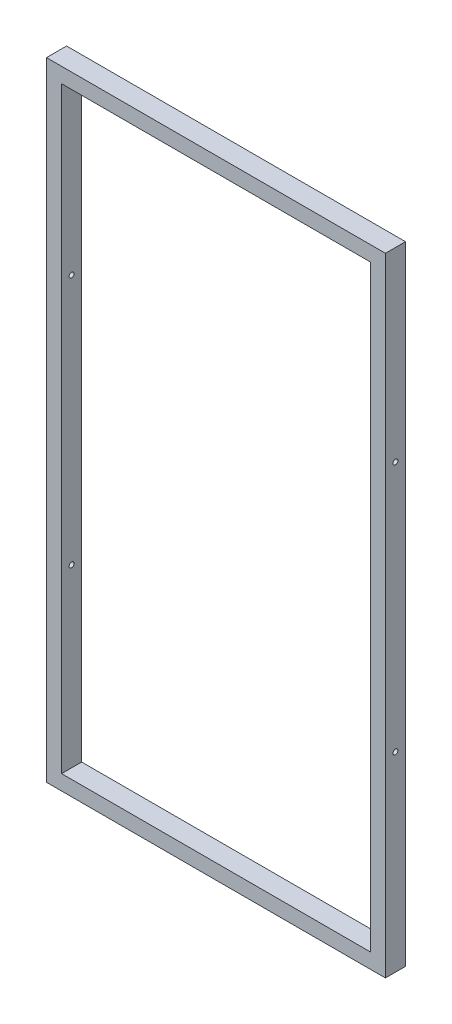
from build123d import *

# Parameters (mm, degrees)
SKETCH_2_W          = 675
SKETCH_2_H          = 1250
SKETCH_2_W_2        = 615
SKETCH_2_H_2        = 1190
EXTRUDE_431_DEPTH   = 40
SKETCH_3_R          = 5
CUT_EXTRUDE_1_DEPTH = 676


with BuildPart() as part:
    # Эскиз2 → Extrude 431 (new body)
    with BuildSketch(Plane.XY):
        with Locations((266.801582525, 586.131528188)):
            Rectangle(SKETCH_2_W, SKETCH_2_H)
        with Locations((266.801582525, 586.131528188)):
            Rectangle(SKETCH_2_W_2, SKETCH_2_H_2, mode=Mode.SUBTRACT)
    extrude(amount=EXTRUDE_431_DEPTH)

    # Эскиз3 → Вырез-Вытянуть1 (cut, through all)
    with BuildSketch(Plane(origin=(604.301582525, 0, 0), x_dir=(0, 0, -1), z_dir=(1, 0, 0))):
        with Locations((-20, 841.131528188)):
            Circle(SKETCH_3_R)
        with Locations((-20, 341.131528188)):
            Circle(SKETCH_3_R)
    extrude(amount=-CUT_EXTRUDE_1_DEPTH, mode=Mode.SUBTRACT)


solid = part.part
